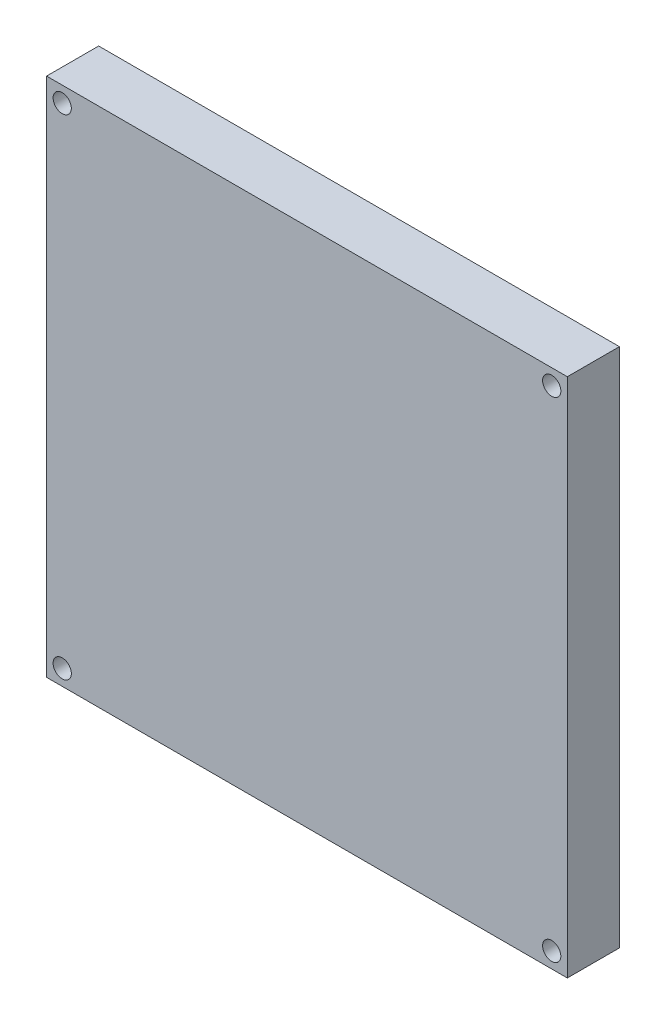
from build123d import *

# Parameters (mm, degrees)
SKETCH1_W           = 100
SKETCH1_H           = 100
BOSS_EXTRUDE1_DEPTH = 10
SKETCH2_R           = 1.75
CUT_EXTRUDE1_DEPTH  = 11


with BuildPart() as part:
    # Sketch1 → Boss-Extrude1 (new body)
    with BuildSketch(Plane.XY):
        with Locations((50, 50)):
            Rectangle(SKETCH1_W, SKETCH1_H)
    extrude(amount=BOSS_EXTRUDE1_DEPTH)

    # Sketch2 → Cut-Extrude1 (cut, through all)
    with BuildSketch(Plane.XY.offset(10)):
        with Locations((97, 97)):
            Circle(SKETCH2_R)
        with Locations((3, 97)):
            Circle(SKETCH2_R)
        with Locations((97, 3)):
            Circle(SKETCH2_R)
        with Locations((3, 3)):
            Circle(SKETCH2_R)
    extrude(amount=-CUT_EXTRUDE1_DEPTH, mode=Mode.SUBTRACT)


solid = part.part
